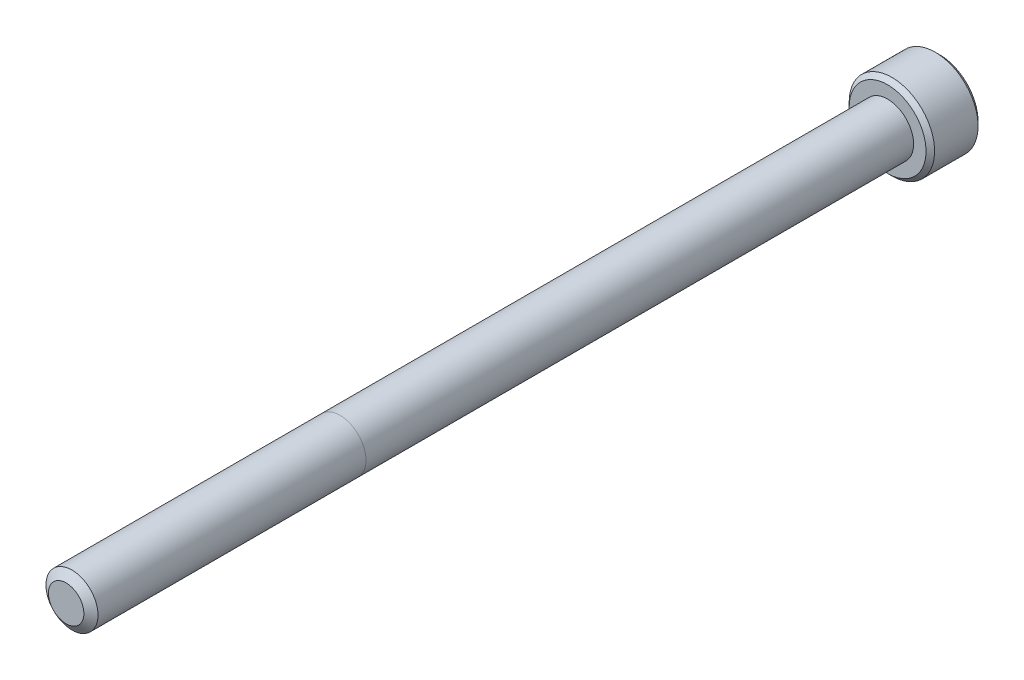
from build123d import *

# Parameters (mm, degrees)
SKETCH1_R          = 2.413
EXTRUDE1_DEPTH     = 76.2
SKETCH6_R          = 3.9624
EXTRUDE2_DEPTH     = 4.826
CUT_EXTRUDE1_DEPTH = 2.9765625
CHAMFER1_SIZE      = 0.39624


with BuildPart() as part:
    # Sketch1 → Extrude1 (new body)
    with BuildSketch(Plane.XY):
        Circle(SKETCH1_R)
    extrude(amount=-EXTRUDE1_DEPTH)

    # Sketch4 → Cut-Revolve1 (revolve, cut)
    with BuildSketch(Plane(origin=(0, 0, 0), x_dir=(0, 0, -1), z_dir=(1, 0, 0))):
        Polygon((0.538848736, 2.413), (0, 1.643444252), (0, 2.413), align=None)
    revolve(axis=Axis((0, 0, 0), (0, 0, -1)), mode=Mode.SUBTRACT)

    # Sketch6 → Extrude2 (add)
    with BuildSketch(Plane(origin=(0, 0, -76.2), x_dir=(-1, 0, 0), z_dir=(0, 0, -1))):
        Circle(SKETCH6_R)
    extrude(amount=EXTRUDE2_DEPTH)

    # Sketch7 → Cut-Extrude1 (cut)
    with BuildSketch(Plane(origin=(0, 0, -81.026), x_dir=(-1, 0, 0), z_dir=(0, 0, -1))):
        Polygon((0, 2.291358881), (-1.984375, 1.14567944), (-1.984375, -1.14567944), (0, -2.291358881), (1.984375, -1.14567944), (1.984375, 1.14567944), align=None)
    extrude(amount=-CUT_EXTRUDE1_DEPTH, mode=Mode.SUBTRACT)

    # Cut-Extrude2 cone 1 section (through the dimple's axis) → Cut-Extrude2 (revolve, cut)
    with BuildSketch(Plane(origin=(0, 0, -81.026), x_dir=(0, 1, 0), z_dir=(1, 0, 0))):
        Polygon((0, 0), (2.291358881, 0), (0, 2.291358881), align=None)
    revolve(axis=Axis((0, 0, -81.026), (0, 0, 1)), mode=Mode.SUBTRACT)

    # Chamfer1
    chamfer1_edges = [part.edges().sort_by_distance(p)[0] for p in [
        (3.9624, 0, -81.026),
        (3.9624, 0, -76.2),
    ]]
    chamfer(chamfer1_edges, length=CHAMFER1_SIZE)


solid = part.part
